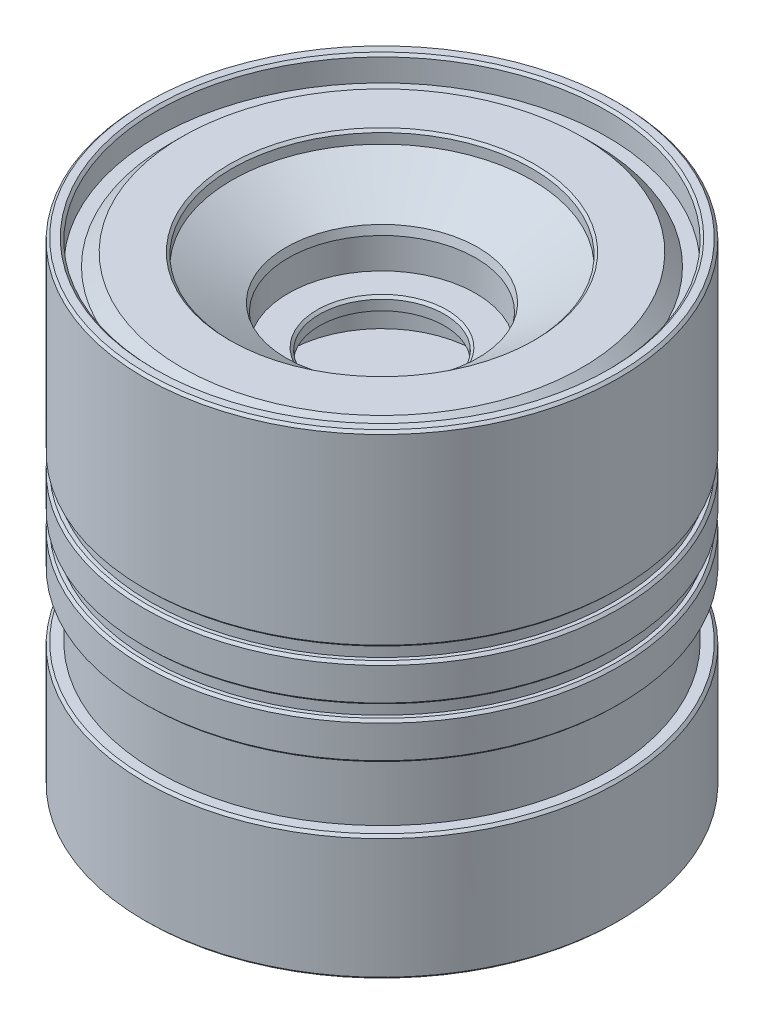
from build123d import *
from OCP.BRepFilletAPI import BRepFilletAPI_MakeChamfer

# Parameters (mm, degrees)
CHAMFER1_SIZE  = 0.2
CHAMFER1_SIZE2 = 0.546410162


with BuildPart() as part:
    # Sketch2 → Revolve1 (revolve)
    with BuildSketch(Plane(origin=(0, 0, 0), x_dir=(0, 0, -1), z_dir=(1, 0, 0))):
        Polygon((-19, 0), (-19, 10), (-18, 10), (-18, 15), (-19, 15), (-19, 18), (-18.5, 18), (-18.5, 19), (-19, 19), (-19, 22), (-18.5, 22), (-18.5, 23), (-19, 23), (-19, 38), (-18, 38), (-18, 36), (-17, 36), (-16, 37), (-12, 37), (-12, 36), (-7.5, 33.401923789), (-7.5, 30.401923789), (-5, 30.401923789), (-5, 29.401923789), (-7.5, 29.401923789), (-7.5, 26.401923789), (0, 26.401923789), (0, 0), align=None)
    revolve(axis=Axis((0, 26.401923789, 0), (0, -1, 0)))

    # Chamfer1: one chamfer whose edges measure the first distance from different faces: ONE call of the kernel's chamfer builder (chamfer() names one face for all edges)
    chamfer1_edges_1 = [part.edges().sort_by_distance(p)[0] for p in [
        (0, 30.401923789, -5),
        (0, 37, -12),
        (0, 38, -18),
        (0, 38, -19),
        (0, 23, -19),
        (0, 22, -19),
        (0, 19, -19),
        (0, 18, -19),
        (0, 15, -19),
        (0, 10, -19),
        (0, 0, -19),
    ]]
    chamfer1_edges_2 = [part.edges().sort_by_distance(p)[0] for p in [
        (0, 33.401923789, -7.5),
    ]]
    chamfer1_side_2 = [part.faces().sort_by_distance(p)[0] for p in [
        (0, 34.700961894, -9.75),
    ]]
    chamfer1 = BRepFilletAPI_MakeChamfer(part.part.solid().wrapped)
    for e in chamfer1_edges_1:
        chamfer1.Add(CHAMFER1_SIZE, e.wrapped)
    for e in chamfer1_edges_2:
        chamfer1.Add(CHAMFER1_SIZE, CHAMFER1_SIZE2, e.wrapped, chamfer1_side_2[0].wrapped)  # the first distance lies on this face
    add(Compound.cast(chamfer1.Shape()), mode=Mode.REPLACE)


solid = part.part
